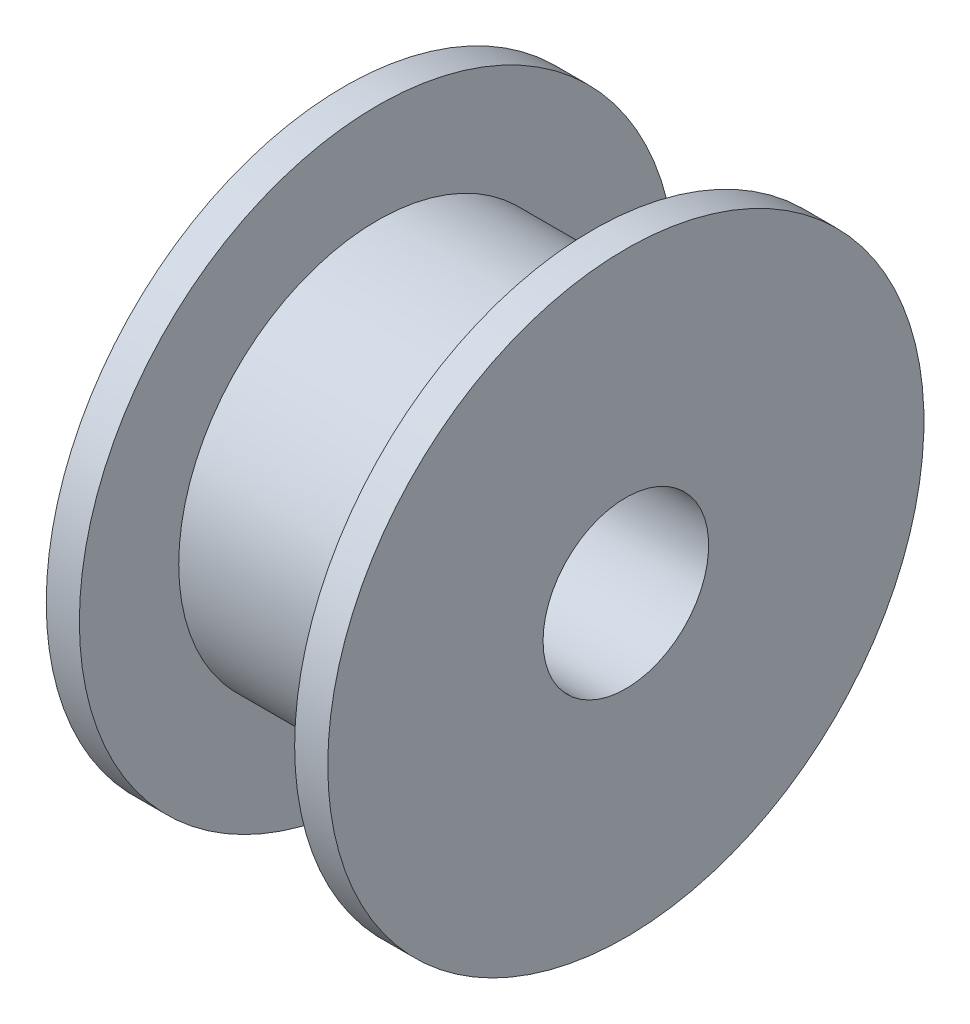
from build123d import *

# Parameters (mm, degrees)
SKETCH2_R          = 2.5
CUT_EXTRUDE1_DEPTH = 9.5


with BuildPart() as part:
    # Sketch1 → Revolve1 (revolve)
    with BuildSketch(Plane.XY):
        Polygon((0, 0), (0, 9), (1, 9), (1, 6), (7.5, 6), (7.5, 9), (8.5, 9), (8.5, 0), align=None)
    revolve(axis=Axis((0, 0, 0), (1, 0, 0)))

    # Sketch2 → Cut-Extrude1 (cut, through all)
    with BuildSketch(Plane.ZY):
        Circle(SKETCH2_R)
    extrude(amount=-CUT_EXTRUDE1_DEPTH, mode=Mode.SUBTRACT)


solid = part.part
